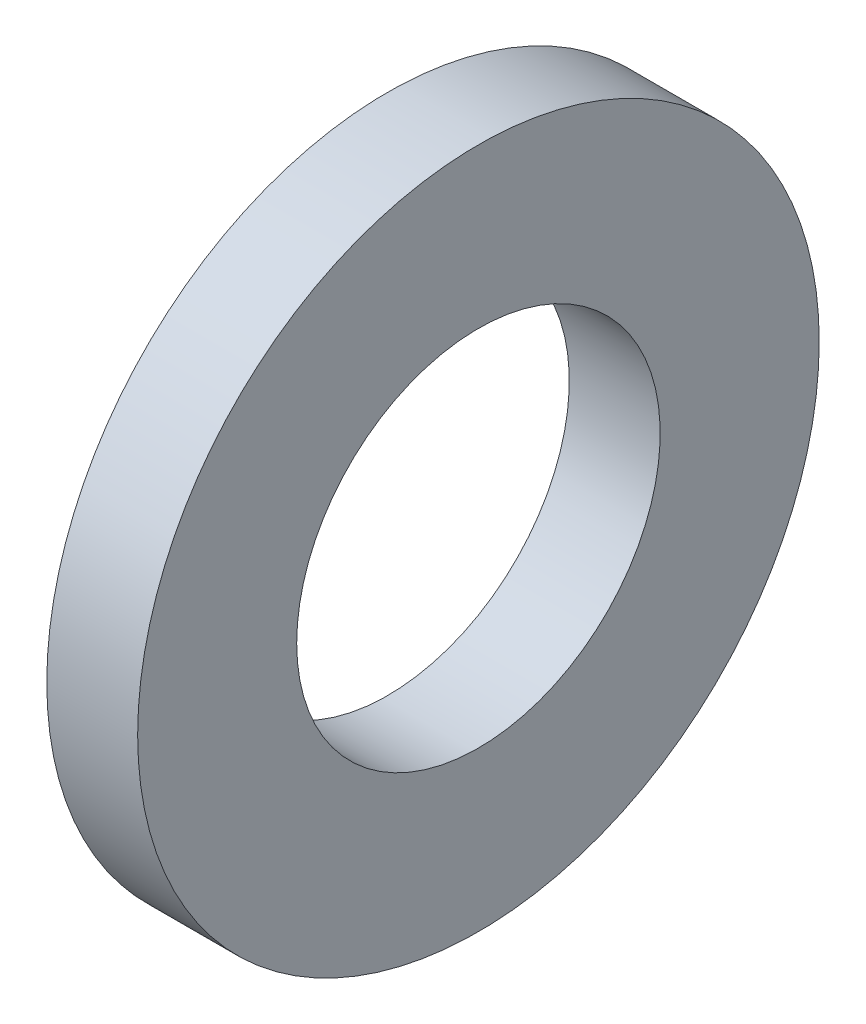
from build123d import *

# Parameters (mm, degrees)
SKETCH1_W = 1.6
SKETCH1_H = 2.8


with BuildPart() as part:
    # Sketch1 → Base-Revolve (revolve)
    with BuildSketch(Plane.XY):
        with Locations((-0.8, 4.6)):
            Rectangle(SKETCH1_W, SKETCH1_H)
    revolve(axis=Axis((-34.925, 0, 0), (1, 0, 0)))


solid = part.part
